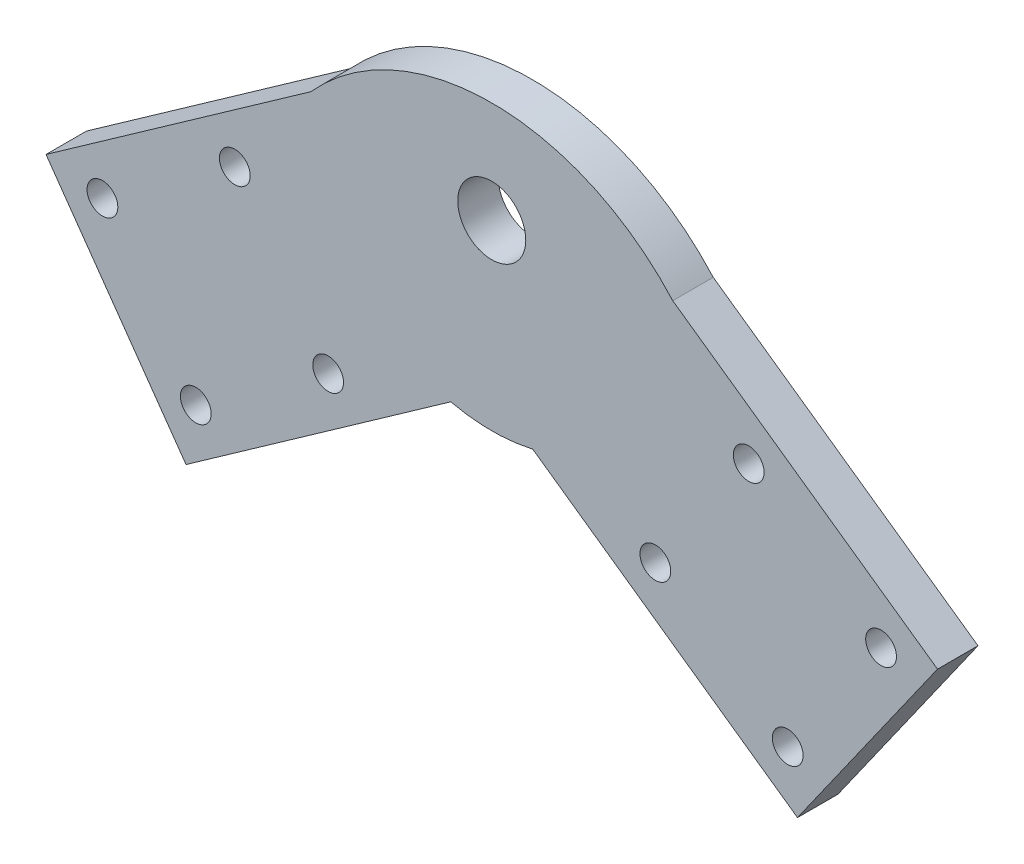
from build123d import *

# Parameters (mm, degrees)
SKETCH2_R            = 4.2
BOSS_EXTRUDE1_DEPTH  = 5
M3_CLEARANCE_HOLE1_D = 3.8


with BuildPart() as part:
    # Sketch2 → Boss-Extrude1 (new body)
    with BuildSketch(Plane.XY):
        with BuildLine():
            Line((5.061398723, -21.923326458), (37.751345105, -44.974734343))
            Line((37.751345105, -44.974734343), (55.039901019, -20.457274556))
            Line((55.039901019, -20.457274556), (22.349954637, 2.594133329))
            ThreePointArc((22.349954637, 2.594133329), (0, 12.582148727), (-22.349954637, 2.594133329))
            Line((-22.349954637, 2.594133329), (-55.039901019, -20.457274556))
            Line((-55.039901019, -20.457274556), (-37.751345105, -44.974734343))
            Line((-37.751345105, -44.974734343), (-5.061398723, -21.923326458))
            ThreePointArc((-5.061398723, -21.923326458), (0, -22.5), (5.061398723, -21.923326458))
        make_face()
        Circle(SKETCH2_R, mode=Mode.SUBTRACT)
    extrude(amount=BOSS_EXTRUDE1_DEPTH)

    # M3 Clearance Hole1 (through all)
    with Locations(Plane.XY.offset(5)):
        with Locations((-31.727258545, -10.136387926), (-20.201554602, -26.481361117), (-36.546527793, -38.00706506), (-48.072231736, -21.662091868), (31.727258545, -10.136387926), (48.072231736, -21.662091868), (20.201554544, -26.481361199), (36.546527736, -38.007065141)):
            Hole(M3_CLEARANCE_HOLE1_D / 2)


solid = part.part
